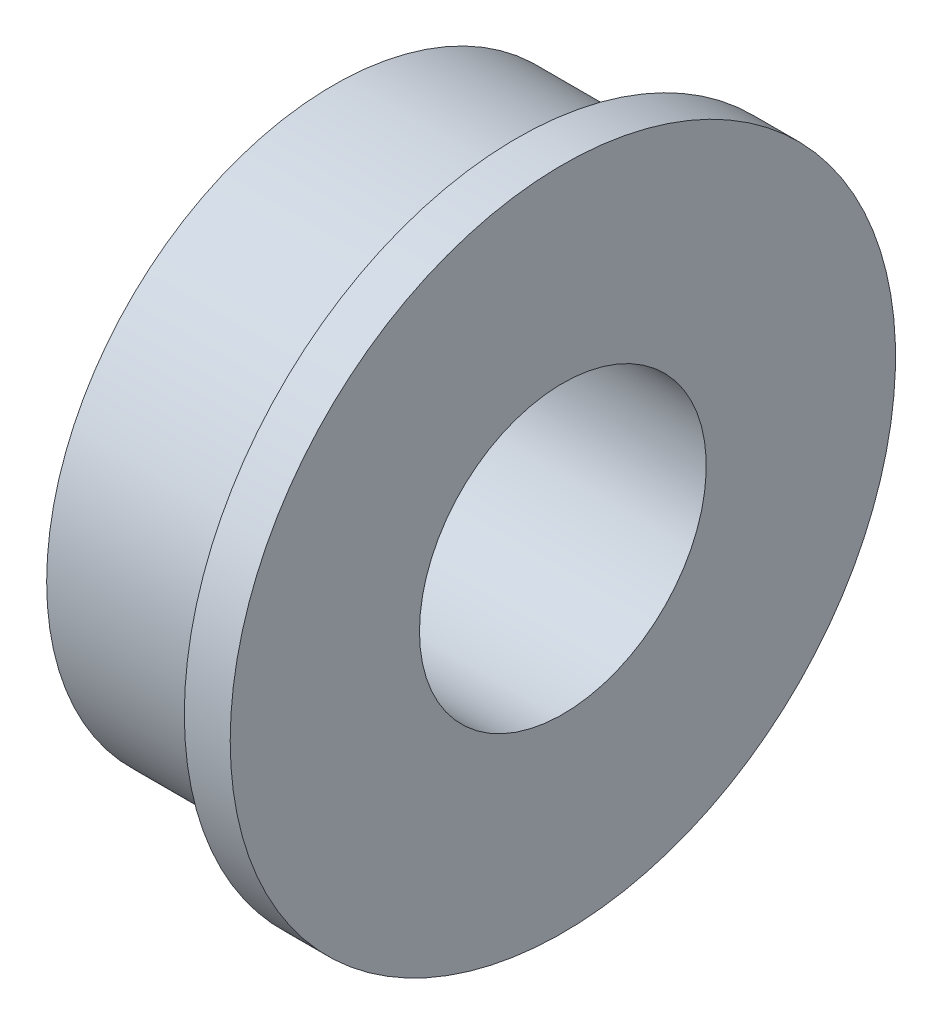
from build123d import *


with BuildPart() as part:
    # Sketch1 → Revolve1 (revolve)
    with BuildSketch(Plane.XY):
        Polygon((-2, 5), (-2, 2.5), (2, 2.5), (2, 5.8), (1.2, 5.8), (1.2, 5), align=None)
    revolve(axis=Axis((-7.872201974, 0, 0), (1, 0, 0)))


solid = part.part
